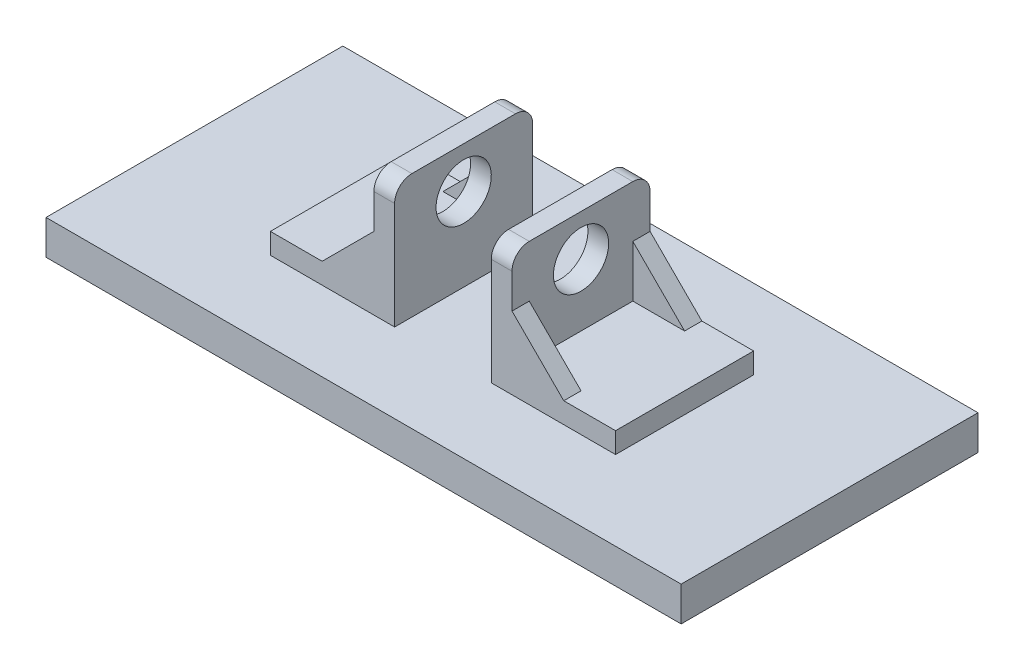
from build123d import *

# Parameters (mm, degrees)
SKETCH1_W           = 184
SKETCH1_H           = 86
PLATE_DEPTH         = 10
BOSS_EXTRUDE1_DEPTH = 20
BOSS_EXTRUDE2_START = 15
BOSS_EXTRUDE2_DEPTH = 5
BOSS_EXTRUDE3_START = -15
BOSS_EXTRUDE3_DEPTH = 5
SKETCH3_R           = 8
CUT_EXTRUDE1_DEPTH  = 40
FILLET1_R           = 5


with BuildPart() as part:
    # Sketch1 → plate (new body)
    with BuildSketch(Plane(origin=(0, 0, 0), x_dir=(1, 0, 0), z_dir=(0, 1, 0))):
        Rectangle(SKETCH1_W, SKETCH1_H)
    extrude(amount=PLATE_DEPTH)

    # Sketch2 → Boss-Extrude1 (add, symmetric)
    with BuildSketch(Plane.XY):
        Polygon((-14, 10), (-14, 46), (-20, 46), (-20, 16), (-50, 16), (-50, 10), align=None)
        Polygon((50, 16), (50, 10), (14, 10), (14, 46), (20, 46), (20, 16), align=None)
    extrude(amount=BOSS_EXTRUDE1_DEPTH, both=True)

    # Sketch2_3 → Boss-Extrude2 (add)
    with BuildSketch(Plane.XY.offset(BOSS_EXTRUDE2_START)):
        Polygon((-20, 16), (-20, 31), (-35, 16), align=None)
        Polygon((35, 16), (20, 31), (20, 16), align=None)
    extrude(amount=BOSS_EXTRUDE2_DEPTH)

    # Sketch2_4 → Boss-Extrude3 (add)
    with BuildSketch(Plane.XY.offset(BOSS_EXTRUDE3_START)):
        Polygon((-20, 16), (-20, 31), (-35, 16), align=None)
        Polygon((35, 16), (20, 31), (20, 16), align=None)
    extrude(amount=-BOSS_EXTRUDE3_DEPTH)

    # Sketch3 → Cut-Extrude1 (cut)
    with BuildSketch(Plane.ZY.offset(20)):
        with Locations((0, 34)):
            Circle(SKETCH3_R)
    extrude(amount=-CUT_EXTRUDE1_DEPTH, mode=Mode.SUBTRACT)

    # Fillet1
    fillet1_edges = [part.edges().sort_by_distance(p)[0] for p in [
        (-17, 46, -20),
        (-17, 46, 20),
        (17, 46, 20),
        (17, 46, -20),
    ]]
    fillet(fillet1_edges, radius=FILLET1_R)


solid = part.part
